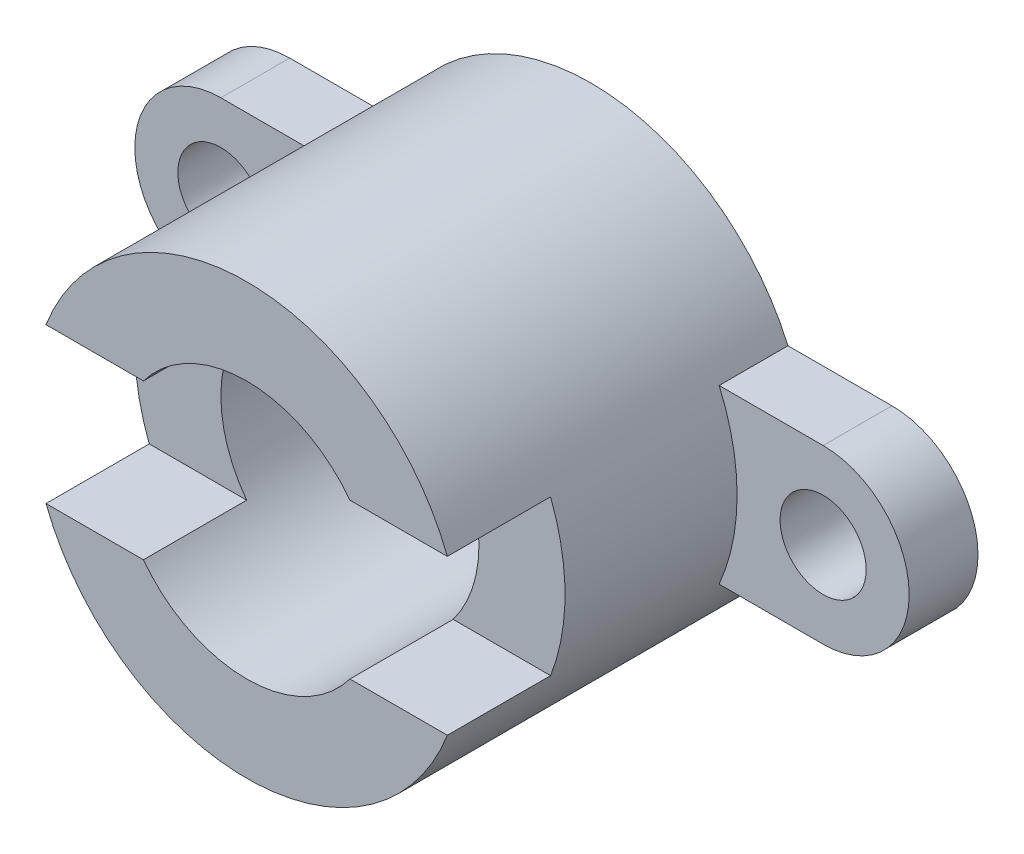
from build123d import *

# Parameters (mm, degrees)
SKETCH1_R           = 15
BOSS_EXTRUDE5_DEPTH = 40
SKETCH1_12_R        = 5
BOSS_EXTRUDE6_DEPTH = 8
SKETCH2_W           = 12
SKETCH2_H           = 18
CUT_EXTRUDE1_DEPTH  = 68


with BuildPart() as part:
    # Sketch1 → Boss-Extrude5 (new body)
    with BuildSketch(Plane.XY):
        with BuildLine():
            ThreePointArc((22.912878475, 10), (0, 25), (-22.912878475, 10))
            ThreePointArc((-22.912878475, 10), (-25, 0), (-22.912878475, -10))
            ThreePointArc((-22.912878475, -10), (0, -25), (22.912878475, -10))
            ThreePointArc((22.912878475, -10), (25, 0), (22.912878475, 10))
        make_face()
        Circle(SKETCH1_R, mode=Mode.SUBTRACT)
    extrude(amount=BOSS_EXTRUDE5_DEPTH)

    # Sketch1_12 → Boss-Extrude6 (add)
    # profile 1 of 2: a face of its own
    with BuildSketch(Plane.XY):
        with BuildLine():
            Line((-22.912878475, 10), (-35, 10))
            ThreePointArc((-35, 10), (-45, 0), (-35, -10))
            Line((-35, -10), (-22.912878475, -10))
            ThreePointArc((-22.912878475, -10), (-25, 0), (-22.912878475, 10))
        make_face()
        with Locations((-35, 0)):
            Circle(SKETCH1_12_R, mode=Mode.SUBTRACT)
    # profile 2 of 2: a face of its own
    with BuildSketch(Plane.XY):
        with BuildLine():
            Line((35, 10), (22.912878475, 10))
            ThreePointArc((22.912878475, 10), (25, 0), (22.912878475, -10))
            Line((22.912878475, -10), (35, -10))
            ThreePointArc((35, -10), (45, 0), (35, 10))
        make_face()
        with Locations((35, 0)):
            Circle(SKETCH1_12_R, mode=Mode.SUBTRACT)
    extrude(amount=BOSS_EXTRUDE6_DEPTH)

    # Sketch2 → Cut-Extrude1 (cut)
    with BuildSketch(Plane(origin=(25, 0, 0), x_dir=(0, 0, -1), z_dir=(1, 0, 0))):
        with Locations((-34, 0)):
            Rectangle(SKETCH2_W, SKETCH2_H)
    extrude(amount=-CUT_EXTRUDE1_DEPTH, mode=Mode.SUBTRACT)


solid = part.part
